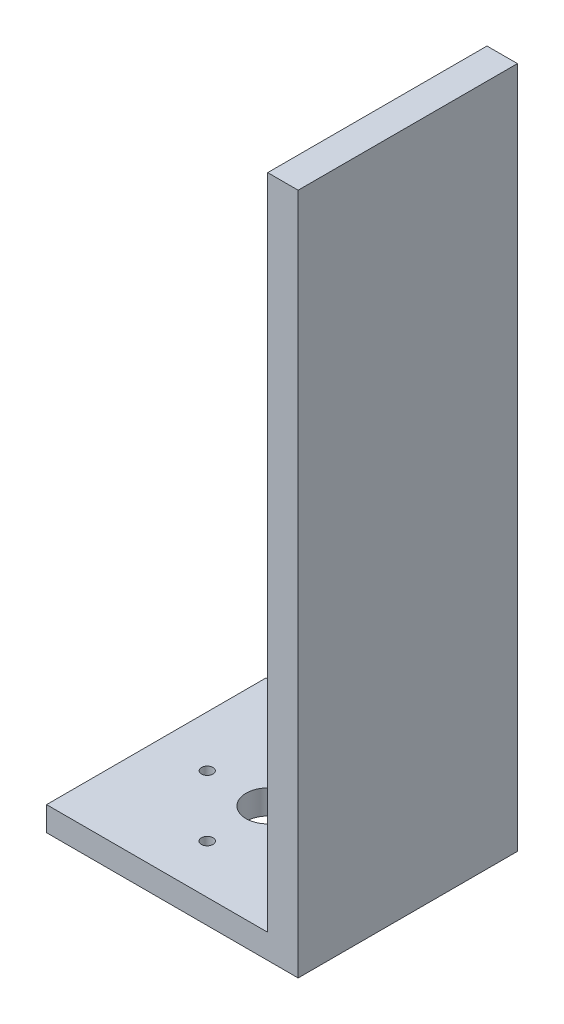
from build123d import *

# Parameters (mm, degrees)
SKETCH_1_W          = 400
SKETCH_1_H          = 90
EXTRUDE_1_DEPTH     = 10
SKETCH_2_R          = 9.063152432
CUT_EXTRUDE_1_DEPTH = 10
SKETCH_3_R          = 1.81023823
SKETCH_3_R_2        = 1.954373085
SKETCH_3_R_3        = 2.399911157
SKETCH_3_R_4        = 2.359906839
CUT_EXTRUDE_2_DEPTH = 10
SKETCH_4_R          = 6.073356137
SKETCH_4_R_2        = 6.104859493
SKETCH_4_R_3        = 4.740379866
CUT_EXTRUDE_3_DEPTH = 10
SKETCH_5_W          = 12.49982796
SKETCH_5_H          = 90
EXTRUDE_2_DEPTH     = 270
SKETCH_6_W          = 148.075925294
SKETCH_6_H          = 90
CUT_EXTRUDE_4_DEPTH = 10
SKETCH_7_W          = 153.736310317
SKETCH_7_H          = 106.42917614
CUT_EXTRUDE_5_DEPTH = 10


with BuildPart() as part:
    # 草图1 → 凸台-拉伸1 (new body)
    with BuildSketch(Plane(origin=(0, 0, 0), x_dir=(1, 0, 0), z_dir=(0, 1, 0))):
        Rectangle(SKETCH_1_W, SKETCH_1_H)
    extrude(amount=EXTRUDE_1_DEPTH)

    # 草图2 → 切除-拉伸1 (cut)
    with BuildSketch(Plane(origin=(0, 10, 0), x_dir=(1, 0, 0), z_dir=(0, 1, 0))):
        with Locations((-6, 0)):
            Circle(SKETCH_2_R)
    extrude(amount=-CUT_EXTRUDE_1_DEPTH, mode=Mode.SUBTRACT)

    # 草图3 → 切除-拉伸2 (cut)
    with BuildSketch(Plane(origin=(0, 10, 0), x_dir=(1, 0, 0), z_dir=(0, 1, 0))):
        with Locations((-6, 25)):
            Circle(SKETCH_3_R)
        with Locations((19, 0)):
            Circle(SKETCH_3_R_2)
        with Locations((-6, -25)):
            Circle(SKETCH_3_R_3)
        with Locations((-31, 0)):
            Circle(SKETCH_3_R_4)
    extrude(amount=-CUT_EXTRUDE_2_DEPTH, mode=Mode.SUBTRACT)

    # 草图4 → 切除-拉伸3 (cut)
    with BuildSketch(Plane(origin=(0, 10, 0), x_dir=(1, 0, 0), z_dir=(0, 1, 0))):
        with Locations((-175, -21.552072621)):
            Circle(SKETCH_4_R)
        with Locations((-135, -21.552072621)):
            Circle(SKETCH_4_R_2)
        with Locations((-155, 23.447927379)):
            Circle(SKETCH_4_R_3)
    extrude(amount=-CUT_EXTRUDE_3_DEPTH, mode=Mode.SUBTRACT)

    # 草图5 → 凸台-拉伸2 (add)
    with BuildSketch(Plane(origin=(0, 10, 0), x_dir=(1, 0, 0), z_dir=(0, 1, 0))):
        with Locations((45.073880923, 0)):
            Rectangle(SKETCH_5_W, SKETCH_5_H)
    extrude(amount=EXTRUDE_2_DEPTH)

    # 草图6 → 切除-拉伸4 (cut)
    with BuildSketch(Plane.XZ):
        with Locations((-125.962037353, 0)):
            Rectangle(SKETCH_6_W, SKETCH_6_H)
    extrude(amount=-CUT_EXTRUDE_4_DEPTH, mode=Mode.SUBTRACT)

    # 草图7 → 切除-拉伸5 (cut)
    with BuildSketch(Plane(origin=(0, 10, 0), x_dir=(1, 0, 0), z_dir=(0, 1, 0))):
        with Locations((128.191950062, -8.21458807)):
            Rectangle(SKETCH_7_W, SKETCH_7_H)
    extrude(amount=-CUT_EXTRUDE_5_DEPTH, mode=Mode.SUBTRACT)


solid = part.part
